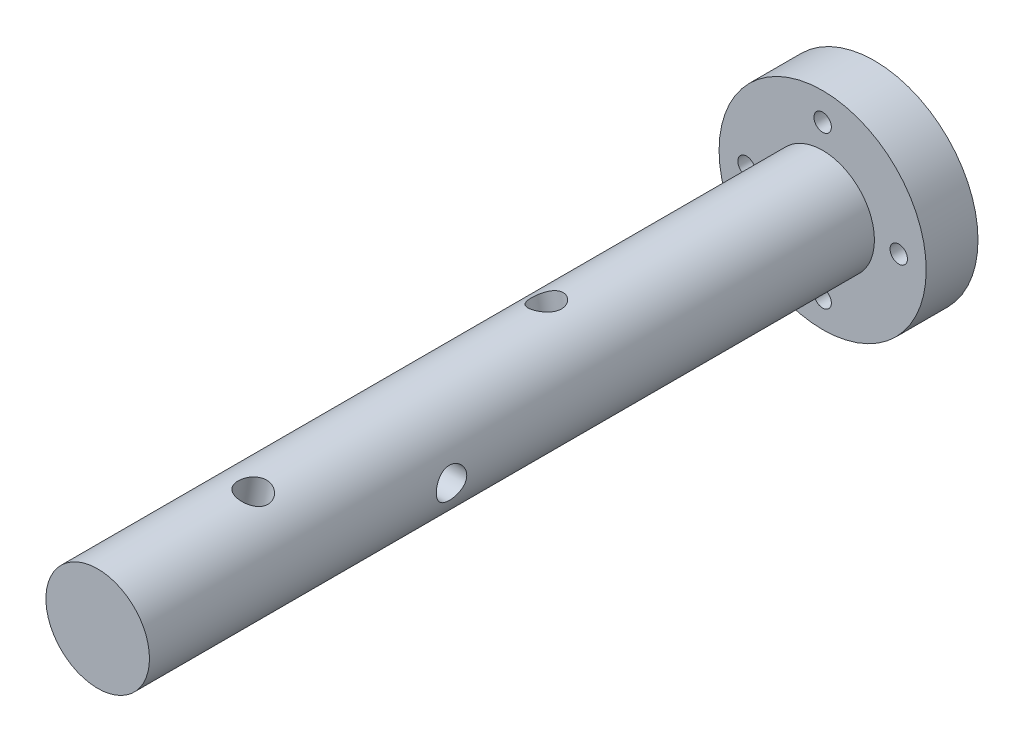
from build123d import *

# Parameters (mm, degrees)
SKETCH1_R               = 4.7625
BOSS_EXTRUDE1_DEPTH     = 66.675
SKETCH1_4_R             = 9.525
SKETCH1_4_R_2           = 3.175
SKETCH1_4_R_3           = 0.800000051
BOSS_EXTRUDE2_DEPTH     = 4.7625
FILLET1_R               = 3.175
CUT_EXTRUDE2_DEPTH      = 69.022105782
CUT_EXTRUDE2_DEPTH_BACK = 69.022105782
SKETCH3_R               = 1.399999994
CUT_EXTRUDE3_DEPTH      = 69.02210588
CUT_EXTRUDE3_DEPTH_BACK = 69.02210588
SKETCH4_R               = 1.399999994
CUT_EXTRUDE4_DEPTH      = 69.02210588
CUT_EXTRUDE4_DEPTH_BACK = 69.02210588
SKETCH5_R               = 1.399999994


with BuildPart() as part:
    # Sketch1 → Boss-Extrude1 (new body)
    with BuildSketch(Plane.XY):
        Circle(SKETCH1_R)
    extrude(amount=BOSS_EXTRUDE1_DEPTH)

    # Sketch1_4 → Boss-Extrude2 (add)
    with BuildSketch(Plane.XY):
        Circle(SKETCH1_4_R)
        Circle(SKETCH1_4_R_2, mode=Mode.SUBTRACT)
        with Locations((0, -6.99999997)):
            Circle(SKETCH1_4_R_3, mode=Mode.SUBTRACT)
        with Locations((6.99999997, 0)):
            Circle(SKETCH1_4_R_3, mode=Mode.SUBTRACT)
        with Locations((-6.99999997, 0)):
            Circle(SKETCH1_4_R_3, mode=Mode.SUBTRACT)
        with Locations((0, 6.99999997)):
            Circle(SKETCH1_4_R_3, mode=Mode.SUBTRACT)
    extrude(amount=-BOSS_EXTRUDE2_DEPTH)

    # Fillet1
    fillet1_edges = [part.edges().sort_by_distance(p)[0] for p in [
        (-3.175, 0, 0),
    ]]
    fillet(fillet1_edges, radius=FILLET1_R)

    # Sketch3 → Cut-Extrude2 (cut, two sides: drawn at the far end of the back side and taken through both)
    with BuildSketch(Plane(origin=(0, 0, 0), x_dir=(0, 0, -1), z_dir=(1, 0, 0)).offset(-CUT_EXTRUDE2_DEPTH_BACK)):
        with Locations((-38.89375, 0)):
            Circle(SKETCH3_R)
    extrude(amount=CUT_EXTRUDE2_DEPTH + CUT_EXTRUDE2_DEPTH_BACK, mode=Mode.SUBTRACT)

    # Sketch4 → Cut-Extrude3 (cut, two sides: drawn at the far end of the back side and taken through both)
    with BuildSketch(Plane(origin=(0, 0, 0), x_dir=(0, 0, -1), z_dir=(0.17364817766693072, 0.984807753012208, 0)).offset(-CUT_EXTRUDE3_DEPTH_BACK)):
        with Locations((-53.18125, 0)):
            Circle(SKETCH4_R)
    extrude(amount=CUT_EXTRUDE3_DEPTH + CUT_EXTRUDE3_DEPTH_BACK, mode=Mode.SUBTRACT)

    # Sketch5 → Cut-Extrude4 (cut, two sides: drawn at the far end of the back side and taken through both)
    with BuildSketch(Plane(origin=(0, 0, 0), x_dir=(0, 0, -1), z_dir=(-0.17364817766693041, 0.9848077530122081, 0)).offset(-CUT_EXTRUDE4_DEPTH_BACK)):
        with Locations((-24.60625, 0)):
            Circle(SKETCH5_R)
    extrude(amount=CUT_EXTRUDE4_DEPTH + CUT_EXTRUDE4_DEPTH_BACK, mode=Mode.SUBTRACT)


solid = part.part
